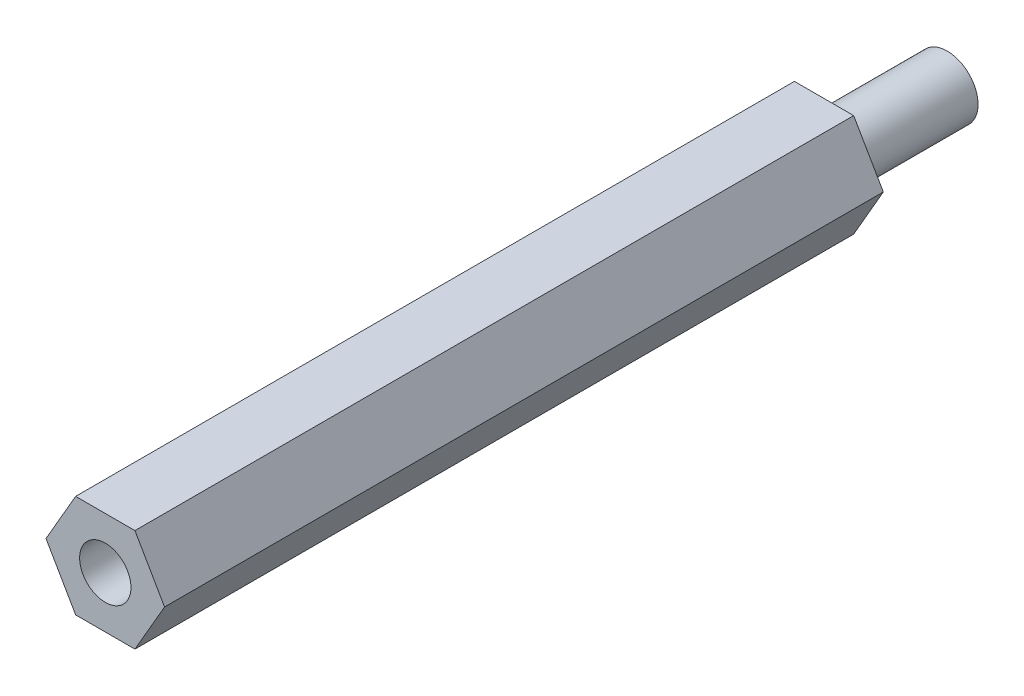
from build123d import *

# Parameters (mm, degrees)
EXTRUDE_1_DEPTH = 35
SKETCH_4_R      = 1.5
EXTRUDE_2_DEPTH = 6
M3X0_5_1_D      = 2.5
M3X0_5_1_DEPTH  = 7.5
M3X0_5_1_TIP    = 0.751075774


with BuildPart() as part:
    # 草圖1 → 填料-伸長1 (new body)
    with BuildSketch(Plane.XY):
        Polygon((-1.443375673, 2.5), (-2.886751346, 0), (-1.443375673, -2.5), (1.443375673, -2.5), (2.886751346, 0), (1.443375673, 2.5), align=None)
    extrude(amount=EXTRUDE_1_DEPTH)

    # 草圖4 → 填料-伸長2 (add)
    with BuildSketch(Plane(origin=(0, 0, 0), x_dir=(-1, 0, 0), z_dir=(0, 0, -1))):
        Circle(SKETCH_4_R)
    extrude(amount=EXTRUDE_2_DEPTH)

    # M3x0.5 螺紋孔1
    with Locations(Plane.XY.offset(35)):
        with Locations((0, 0)):
            Hole(M3X0_5_1_D / 2, depth=M3X0_5_1_DEPTH)
            with Locations((0, 0, -(M3X0_5_1_DEPTH + M3X0_5_1_TIP / 2))):  # 118° drill point
                Cone(0, M3X0_5_1_D / 2, M3X0_5_1_TIP, mode=Mode.SUBTRACT)


solid = part.part
